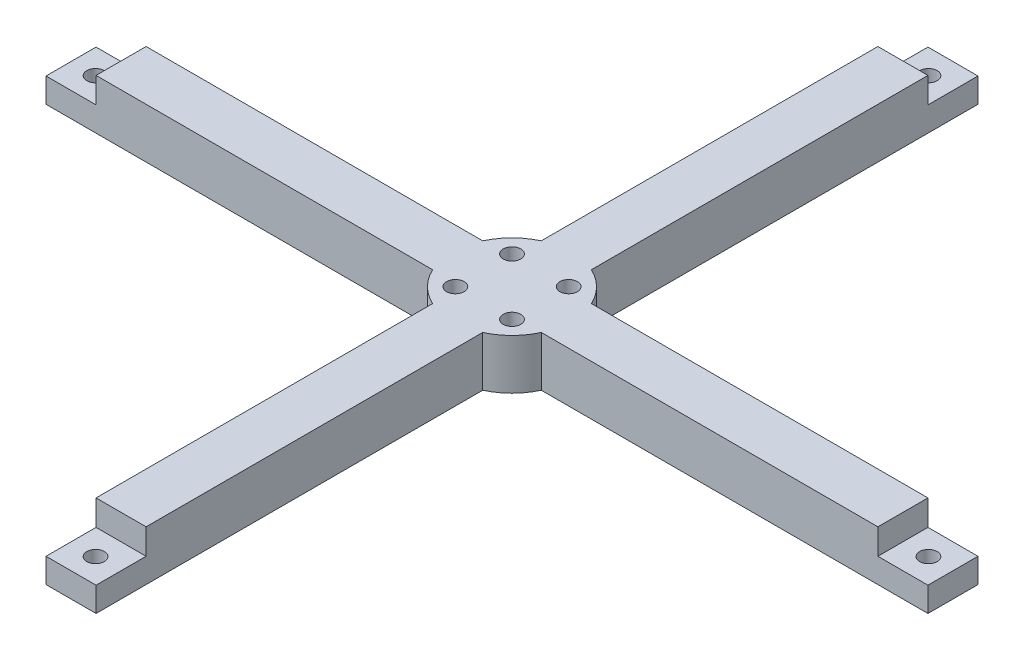
from build123d import *

# Parameters (mm, degrees)
SKETCH1_R           = 11.95
BOSS_EXTRUDE1_DEPTH = 10
BOSS_EXTRUDE2_DEPTH = 10
CUT_EXTRUDE2_DEPTH  = 17.95
SKETCH6_R           = 1.75
CUT_EXTRUDE4_DEPTH  = 10
CIRPATTERN2_COUNT   = 4
SKETCH5_R           = 1.75
CUT_EXTRUDE3_DEPTH  = 11


with BuildPart() as part:
    # Sketch1 → Boss-Extrude1 (new body)
    with BuildSketch(Plane(origin=(0, 0, 0), x_dir=(1, 0, 0), z_dir=(0, 1, 0))):
        Circle(SKETCH1_R)
    extrude(amount=BOSS_EXTRUDE1_DEPTH)

    # Sketch2 → Boss-Extrude2 (add)
    with BuildSketch(Plane(origin=(0, 10, 0), x_dir=(1, 0, 0), z_dir=(0, 1, 0))):
        with BuildLine():
            Line((10.85368601, -5), (98.2, -5))
            Line((98.2, -5), (98.2, 5))
            Line((98.2, 5), (10.85368601, 5))
            ThreePointArc((10.85368601, 5), (11.95, 0), (10.85368601, -5))
        make_face()
    boss_extrude2 = extrude(amount=-BOSS_EXTRUDE2_DEPTH)

    # Sketch4 → Cut-Extrude2 (cut, through all)
    with BuildSketch(Plane.XY.offset(5)):
        Polygon((88.1, 0), (88.1, 4.9), (78.1, 4.9), (78.1, 10), (98.2, 10), (98.2, 0), align=None)
    cut_extrude2 = extrude(amount=-CUT_EXTRUDE2_DEPTH, mode=Mode.SUBTRACT)

    # Sketch6 → Cut-Extrude4 (cut)
    with BuildSketch(Plane(origin=(0, 4.9, 0), x_dir=(1, 0, 0), z_dir=(0, 1, 0))):
        with Locations((83.2, 0)):
            Circle(SKETCH6_R)
    cut_extrude4 = extrude(amount=-CUT_EXTRUDE4_DEPTH, mode=Mode.SUBTRACT)

    # CirPattern2: Boss-Extrude2, Cut-Extrude2, Cut-Extrude4 ×4 about axis
    cirpattern2_axis = Axis((0, 0, 0), (0, 1, 0))
    for i in range(1, CIRPATTERN2_COUNT):
        add(boss_extrude2.rotate(cirpattern2_axis, i * 360 / CIRPATTERN2_COUNT))
        add(cut_extrude2.rotate(cirpattern2_axis, i * 360 / CIRPATTERN2_COUNT), mode=Mode.SUBTRACT)
        add(cut_extrude4.rotate(cirpattern2_axis, i * 360 / CIRPATTERN2_COUNT), mode=Mode.SUBTRACT)

    # Sketch5 → Cut-Extrude3 (cut, through all)
    with BuildSketch(Plane(origin=(0, 10, 0), x_dir=(1, 0, 0), z_dir=(0, 1, 0))):
        with Locations((5.656854249, 5.656854249)):
            Circle(SKETCH5_R)
        with Locations((5.656854249, -5.656854249)):
            Circle(SKETCH5_R)
        with Locations((-5.656854249, -5.656854249)):
            Circle(SKETCH5_R)
        with Locations((-5.656854249, 5.656854249)):
            Circle(SKETCH5_R)
    extrude(amount=-CUT_EXTRUDE3_DEPTH, mode=Mode.SUBTRACT)


solid = part.part
